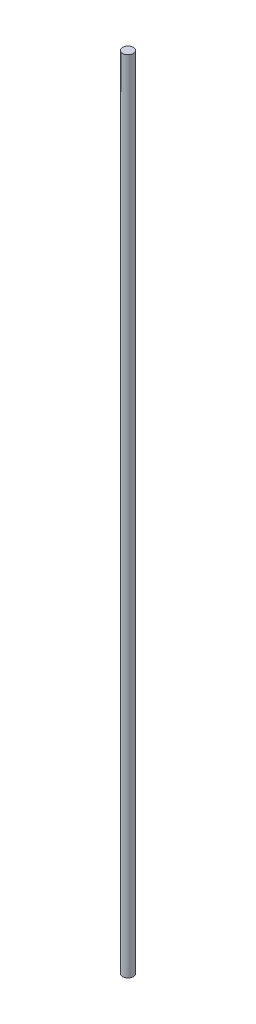
from build123d import *

# Parameters (mm, degrees)
SKETCH1_R           = 3.175
BOSS_EXTRUDE1_DEPTH = 475


with BuildPart() as part:
    # Sketch1 → Boss-Extrude1 (new body)
    with BuildSketch(Plane(origin=(0, 0, 0), x_dir=(1, 0, 0), z_dir=(0, 1, 0))):
        Circle(SKETCH1_R)
    extrude(amount=BOSS_EXTRUDE1_DEPTH)


solid = part.part
